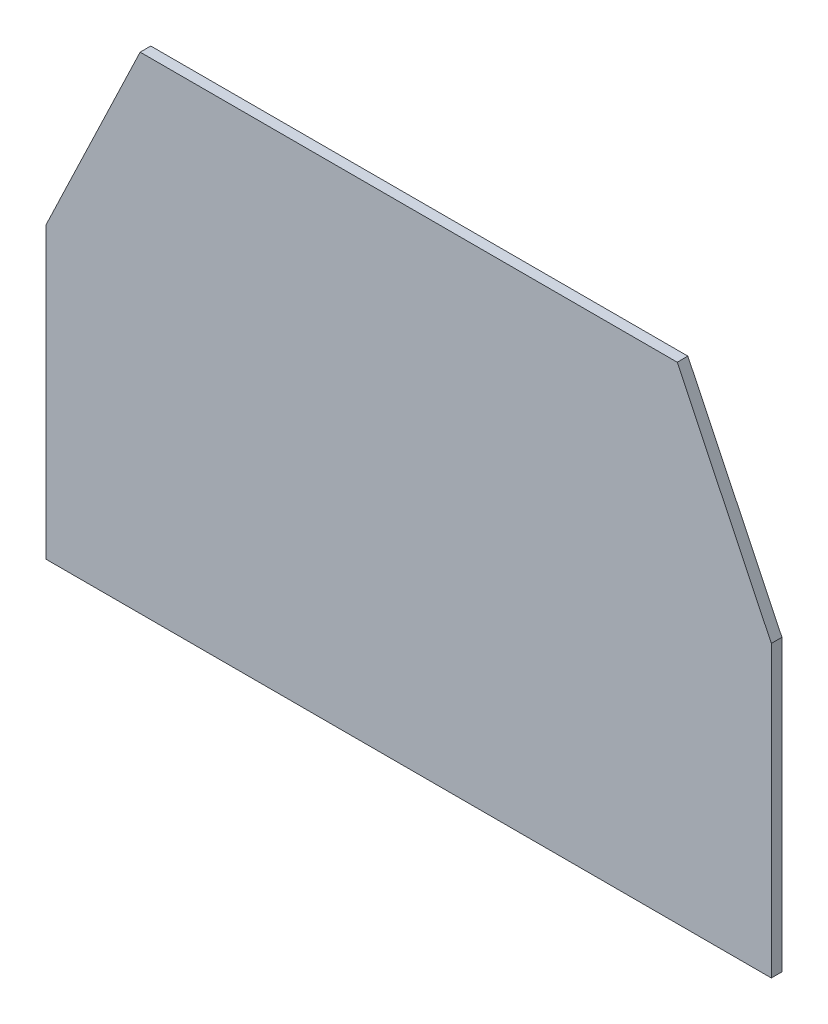
from build123d import *

# Parameters (mm, degrees)
AUFSATZ_LINEAR_AUSTRAGEN1_DEPTH = 10


with BuildPart() as part:
    # Skizze1 → Aufsatz-Linear austragen1 (new body)
    with BuildSketch(Plane.XY):
        Polygon((341.858259494, -194.367647059), (-341.858259494, -194.367647059), (-341.858259494, 78.794563683), (-253.156995608, 264.02367356), (253.156995608, 264.02367356), (341.858259494, 78.794563683), align=None)
    extrude(amount=AUFSATZ_LINEAR_AUSTRAGEN1_DEPTH)


solid = part.part
